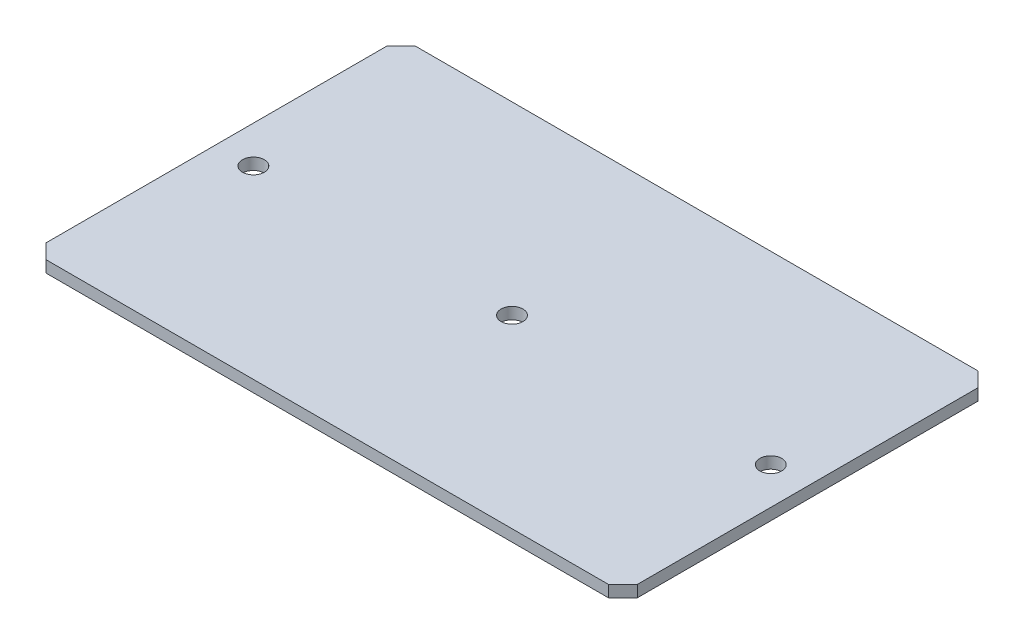
from build123d import *

# Parameters (mm, degrees)
SKETCH1_W           = 81.28
SKETCH1_H           = 50.8
BOSS_EXTRUDE1_DEPTH = 1.6002
SKETCH2_R           = 1.5
CUT_EXTRUDE1_DEPTH  = 1.6002
CHAMFER1_SIZE       = 2


with BuildPart() as part:
    # Sketch1 → Boss-Extrude1 (new body)
    with BuildSketch(Plane(origin=(0, 0, 0), x_dir=(1, 0, 0), z_dir=(0, 1, 0))):
        Rectangle(SKETCH1_W, SKETCH1_H)
    extrude(amount=BOSS_EXTRUDE1_DEPTH)

    # Sketch2 → Cut-Extrude1 (cut)
    with BuildSketch(Plane(origin=(0, 1.6002, 0), x_dir=(1, 0, 0), z_dir=(0, 1, 0))):
        with Locations((-35.54, 0)):
            Circle(SKETCH2_R)
        with Locations((35.56, 0)):
            Circle(SKETCH2_R)
        Circle(SKETCH2_R)
    extrude(amount=-CUT_EXTRUDE1_DEPTH, mode=Mode.SUBTRACT)

    # Chamfer1
    chamfer1_edges = [part.edges().sort_by_distance(p)[0] for p in [
        (40.64, 0.8001, 25.4),
        (-40.64, 0.8001, 25.4),
        (-40.64, 0.8001, -25.4),
        (40.64, 0.8001, -25.4),
    ]]
    chamfer(chamfer1_edges, length=CHAMFER1_SIZE)


solid = part.part
